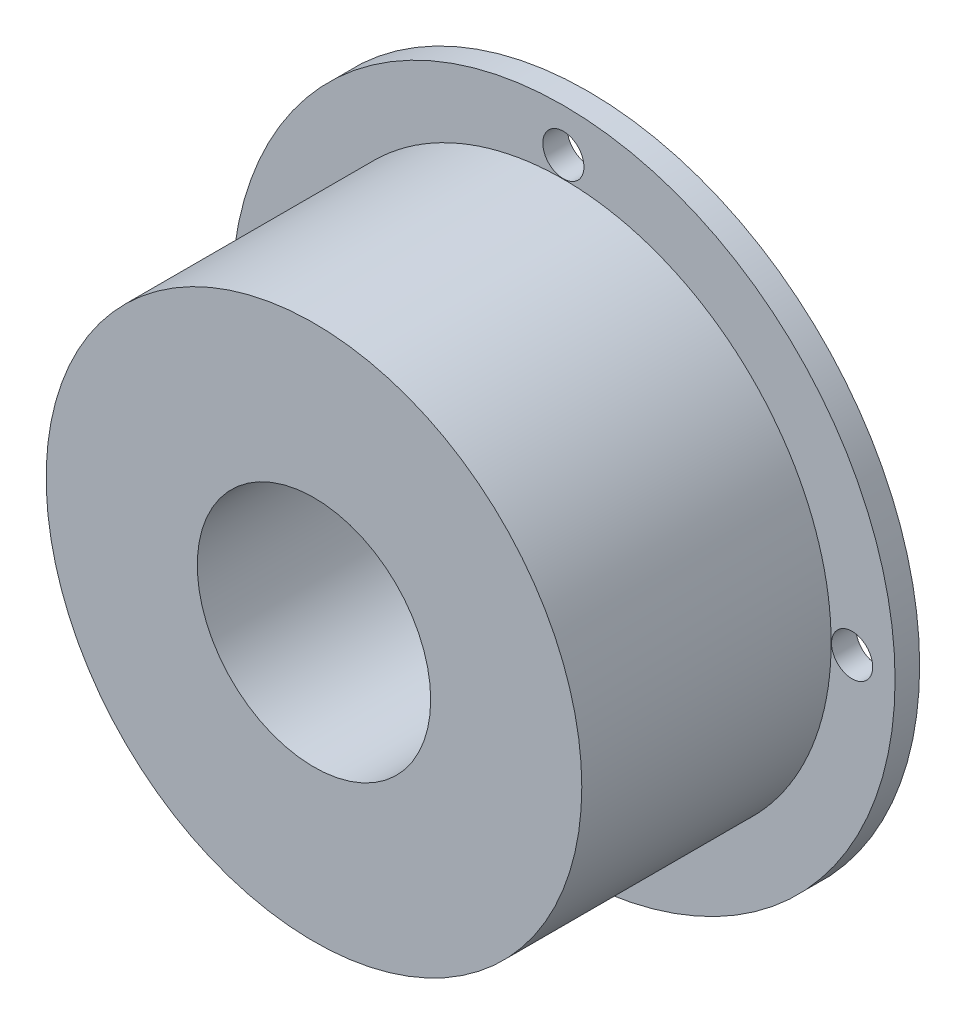
from build123d import *

# Parameters (mm, degrees)
SKETCH_1_R      = 21.8
SKETCH_1_R_2    = 9.5
EXTRUDE_1_DEPTH = 22.3
SKETCH_2_R      = 27
SKETCH_2_R_2    = 21.8
SKETCH_2_R_3    = 1.675
EXTRUDE_2_DEPTH = 2


with BuildPart() as part:
    # 草圖1 → 填料-伸長1 (new body)
    with BuildSketch(Plane.XY):
        Circle(SKETCH_1_R)
        Circle(SKETCH_1_R_2, mode=Mode.SUBTRACT)
    extrude(amount=EXTRUDE_1_DEPTH)


with BuildPart() as body_2:
    # 草圖2 → 填料-伸長2 (new body)
    with BuildSketch(Plane(origin=(0, 0, 0), x_dir=(-1, 0, 0), z_dir=(0, 0, -1))):
        Circle(SKETCH_2_R)
        Circle(SKETCH_2_R_2, mode=Mode.SUBTRACT)
        with Locations((0, 23.5)):
            Circle(SKETCH_2_R_3, mode=Mode.SUBTRACT)
        with Locations((0, -23.5)):
            Circle(SKETCH_2_R_3, mode=Mode.SUBTRACT)
        with Locations((23.5, 0)):
            Circle(SKETCH_2_R_3, mode=Mode.SUBTRACT)
        with Locations((-23.5, 0)):
            Circle(SKETCH_2_R_3, mode=Mode.SUBTRACT)
    extrude(amount=-EXTRUDE_2_DEPTH)


solid = Compound([part.part, body_2.part])
